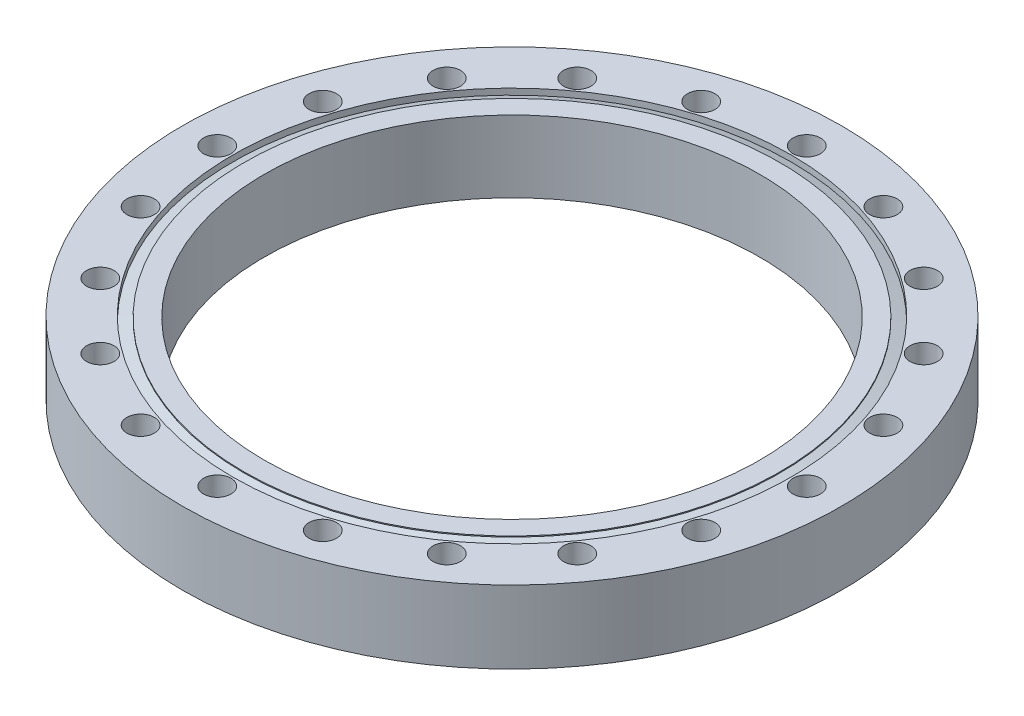
from build123d import *

# Parameters (mm, degrees)
SKETCH2_W         = 4.2164
SKETCH2_H         = 22.352
CIRPATTERN1_COUNT = 20


with BuildPart() as part:
    # Sketch1 → Revolve1 (revolve)
    with BuildSketch(Plane.XY):
        Polygon((101.219, 11.176), (101.219, -11.176), (76.073, -11.176), (76.073, 10.852161676), (82.296, 10.852161676), (82.296, 10.541), (85.725, 9.292946067), (85.725, 11.176), align=None)
    revolve(axis=Axis((0, 42.36922773, 0), (0, -1, 0)))

    # Sketch2 → Cut-Revolve1 (revolve, cut)
    with BuildSketch(Plane.XY):
        with Locations((92.6338, 0)):
            Rectangle(SKETCH2_W, SKETCH2_H)
    cut_revolve1 = revolve(axis=Axis((90.5256, 40.326048615, 0), (0, -1, 0)), mode=Mode.SUBTRACT)

    # CirPattern1: Cut-Revolve1 ×20 about axis
    cirpattern1_axis = Axis((0, -33.88604829, 0), (0, 1, 0))
    for i in range(1, CIRPATTERN1_COUNT):
        add(cut_revolve1.rotate(cirpattern1_axis, i * 360 / CIRPATTERN1_COUNT), mode=Mode.SUBTRACT)


solid = part.part
